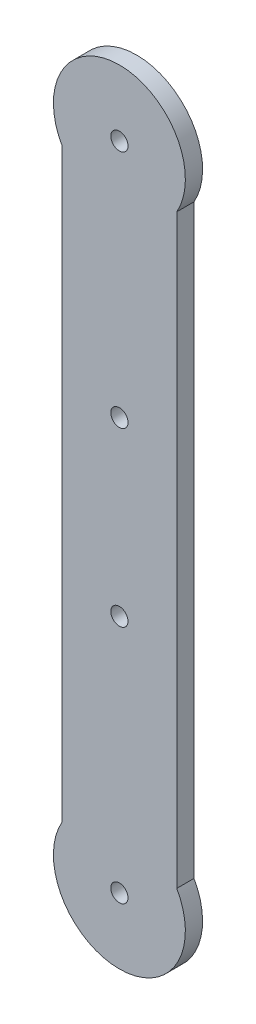
from build123d import *

# Parameters (mm, degrees)
SALIENTE_EXTRUIR1_DEPTH = 3
CROQUIS2_R              = 1.5
CORTAR_EXTRUIR1_DEPTH   = 4


with BuildPart() as part:
    # Croquis1 → Saliente-Extruir1 (new body)
    with BuildSketch(Plane.XY):
        with BuildLine():
            ThreePointArc((-10, -51.071091654), (0, -45.25), (10, -51.071091654))
            Line((10, -51.071091654), (10, 51.071091654))
            ThreePointArc((10, 51.071091654), (0, 45.25), (-10, 51.071091654))
            Line((-10, 51.071091654), (-10, -51.071091654))
        make_face()
        with BuildLine():
            ThreePointArc((-10, 51.071091654), (0, 45.25), (10, 51.071091654))
            Line((10, 51.071091654), (10, 56.75))
            Line((10, 56.75), (-10, 56.75))
            Line((-10, 56.75), (-10, 51.071091654))
        make_face()
        with BuildLine():
            Line((10, 56.75), (10, 51.071091654))
            ThreePointArc((10, 51.071091654), (11.118677979, 53.813164969), (11.5, 56.75))
            ThreePointArc((11.5, 56.75), (-2.936835031, 67.868677979), (-10, 51.071091654))
            Line((-10, 51.071091654), (-10, 56.75))
            Line((-10, 56.75), (10, 56.75))
        make_face()
        with BuildLine():
            Line((10, -51.071091654), (10, -56.75))
            Line((10, -56.75), (-10, -56.75))
            Line((-10, -56.75), (-10, -51.071091654))
            ThreePointArc((-10, -51.071091654), (-2.936835031, -67.868677979), (11.5, -56.75))
            ThreePointArc((11.5, -56.75), (11.118677979, -53.813164969), (10, -51.071091654))
        make_face()
        with BuildLine():
            Line((-10, -56.75), (10, -56.75))
            Line((10, -56.75), (10, -51.071091654))
            ThreePointArc((10, -51.071091654), (0, -45.25), (-10, -51.071091654))
            Line((-10, -51.071091654), (-10, -56.75))
        make_face()
    extrude(amount=SALIENTE_EXTRUIR1_DEPTH)

    # Croquis2 → Cortar-Extruir1 (cut, through all)
    with BuildSketch(Plane.XY.offset(3)):
        with Locations((0, 15)):
            Circle(CROQUIS2_R)
        with Locations((0, -15)):
            Circle(CROQUIS2_R)
        with Locations((0, 56.75)):
            Circle(CROQUIS2_R)
        with Locations((0, -56.75)):
            Circle(CROQUIS2_R)
    extrude(amount=-CORTAR_EXTRUIR1_DEPTH, mode=Mode.SUBTRACT)


solid = part.part
